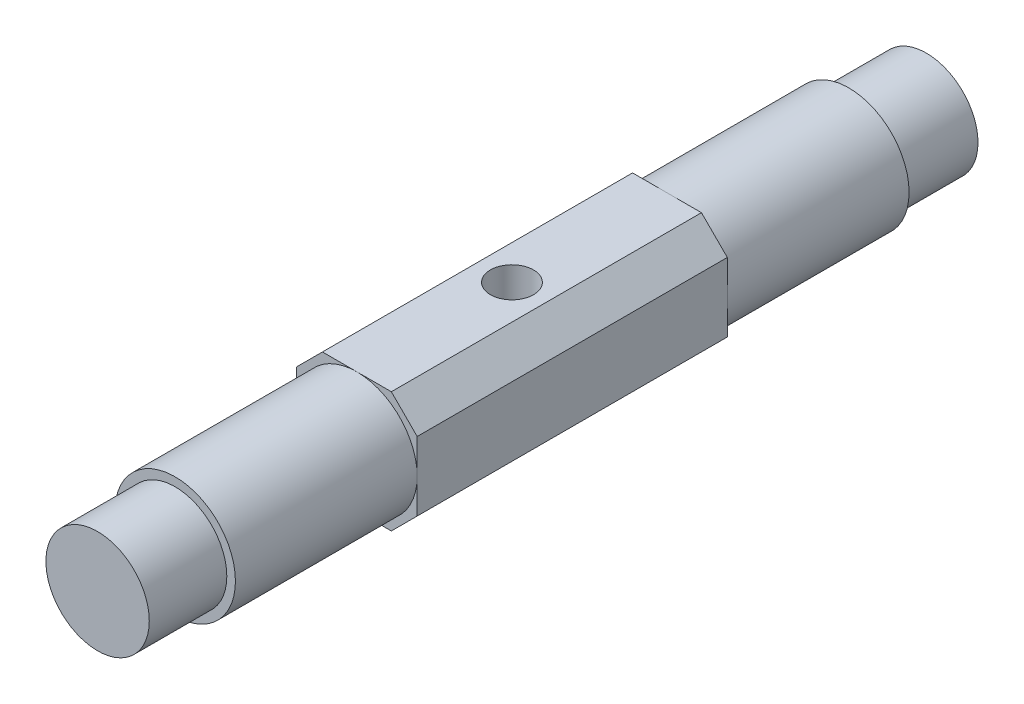
from build123d import *

# Parameters (mm, degrees)
CROQUIS1_R              = 3
SALIENTE_EXTRUIR1_DEPTH = 4.5
CROQUIS2_R              = 3.5
SALIENTE_EXTRUIR2_DEPTH = 10.55
CROQUIS3_W              = 7
CROQUIS3_H              = 7
SALIENTE_EXTRUIR3_DEPTH = 18
CROQUIS4_R              = 3.5
SALIENTE_EXTRUIR4_DEPTH = 10.55
CROQUIS5_R              = 3
SALIENTE_EXTRUIR5_DEPTH = 4.5
CROQUIS6_R              = 1.25
CORTAR_EXTRUIR1_DEPTH   = 8
CHAFL_N1_SIZE           = 1.5


with BuildPart() as part:
    # Croquis1 → Saliente-Extruir1 (new body)
    with BuildSketch(Plane.XY):
        Circle(CROQUIS1_R)
    extrude(amount=SALIENTE_EXTRUIR1_DEPTH)

    # Croquis2 → Saliente-Extruir2 (add)
    with BuildSketch(Plane.XY.offset(4.5)):
        Circle(CROQUIS2_R)
    extrude(amount=SALIENTE_EXTRUIR2_DEPTH)

    # Croquis3 → Saliente-Extruir3 (add)
    with BuildSketch(Plane.XY.offset(15.05)):
        Rectangle(CROQUIS3_W, CROQUIS3_H)
    extrude(amount=SALIENTE_EXTRUIR3_DEPTH)

    # Croquis4 → Saliente-Extruir4 (add)
    with BuildSketch(Plane.XY.offset(33.05)):
        Circle(CROQUIS4_R)
    extrude(amount=SALIENTE_EXTRUIR4_DEPTH)

    # Croquis5 → Saliente-Extruir5 (add)
    with BuildSketch(Plane.XY.offset(43.6)):
        Circle(CROQUIS5_R)
    extrude(amount=SALIENTE_EXTRUIR5_DEPTH)

    # Croquis6 → Cortar-Extruir1 (cut, through all)
    with BuildSketch(Plane(origin=(0, 3.5, 0), x_dir=(1, 0, 0), z_dir=(0, 1, 0))):
        with Locations((0, -24.05)):
            Circle(CROQUIS6_R)
    extrude(amount=-CORTAR_EXTRUIR1_DEPTH, mode=Mode.SUBTRACT)

    # Chaflán1
    chafl_n1_edges = [part.edges().sort_by_distance(p)[0] for p in [
        (3.5, -3.5, 24.05),
        (3.5, 3.5, 24.05),
        (-3.5, 3.5, 24.05),
        (-3.5, -3.5, 24.05),
    ]]
    chamfer(chafl_n1_edges, length=CHAFL_N1_SIZE)


solid = part.part
